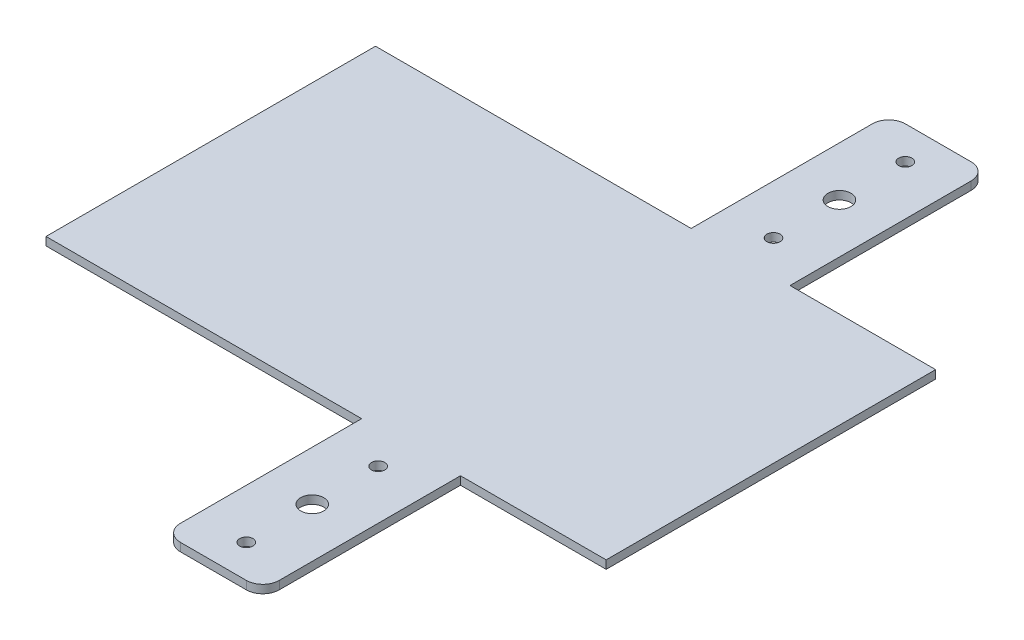
from build123d import *

# Parameters (mm, degrees)
SKETCH1_R           = 7
BOSS_EXTRUDE1_DEPTH = 5
SKETCH2_R           = 4
CUT_EXTRUDE1_DEPTH  = 6


with BuildPart() as part:
    # Sketch1 → Boss-Extrude1 (new body)
    with BuildSketch(Plane(origin=(0, 0, 0), x_dir=(1, 0, 0), z_dir=(0, 1, 0))):
        with BuildLine():
            Line((-449.708642176, 415.631578947), (-361.296475424, 415.631578947))
            Line((-361.296475424, 415.631578947), (-361.296475424, 215.631578947))
            Line((-361.296475424, 215.631578947), (-449.708642176, 215.631578947))
            Line((-449.708642176, 215.631578947), (-449.708642176, 105.631578947))
            ThreePointArc((-449.708642176, 105.631578947), (-452.637574364, 98.560511136), (-459.708642176, 95.631578947))
            Line((-459.708642176, 95.631578947), (-499.708642176, 95.631578947))
            ThreePointArc((-499.708642176, 95.631578947), (-506.779709988, 98.560511136), (-509.708642176, 105.631578947))
            Line((-509.708642176, 105.631578947), (-509.708642176, 215.631578947))
            Line((-509.708642176, 215.631578947), (-701.296475424, 215.631578947))
            Line((-701.296475424, 215.631578947), (-701.296475424, 415.631578947))
            Line((-701.296475424, 415.631578947), (-509.708642176, 415.631578947))
            Line((-509.708642176, 415.631578947), (-509.708642176, 525.631578947))
            ThreePointArc((-509.708642176, 525.631578947), (-506.779709988, 532.702646759), (-499.708642176, 535.631578947))
            Line((-499.708642176, 535.631578947), (-459.708642176, 535.631578947))
            ThreePointArc((-459.708642176, 535.631578947), (-452.637574364, 532.702646759), (-449.708642176, 525.631578947))
            Line((-449.708642176, 525.631578947), (-449.708642176, 415.631578947))
        make_face()
        with Locations((-479.708642176, 475.631578947)):
            Circle(SKETCH1_R, mode=Mode.SUBTRACT)
        with Locations((-479.708642176, 155.631578947)):
            Circle(SKETCH1_R, mode=Mode.SUBTRACT)
    extrude(amount=BOSS_EXTRUDE1_DEPTH)

    # Sketch2 → Cut-Extrude1 (cut, through all)
    with BuildSketch(Plane(origin=(0, 5, 0), x_dir=(1, 0, 0), z_dir=(0, 1, 0))):
        with Locations((-479.708642176, 195.631578947)):
            Circle(SKETCH2_R)
        with Locations((-479.708642176, 115.631578947)):
            Circle(SKETCH2_R)
        with Locations((-479.708642176, 515.631578947)):
            Circle(SKETCH2_R)
        with Locations((-479.708642176, 435.631578947)):
            Circle(SKETCH2_R)
    extrude(amount=-CUT_EXTRUDE1_DEPTH, mode=Mode.SUBTRACT)


solid = part.part
